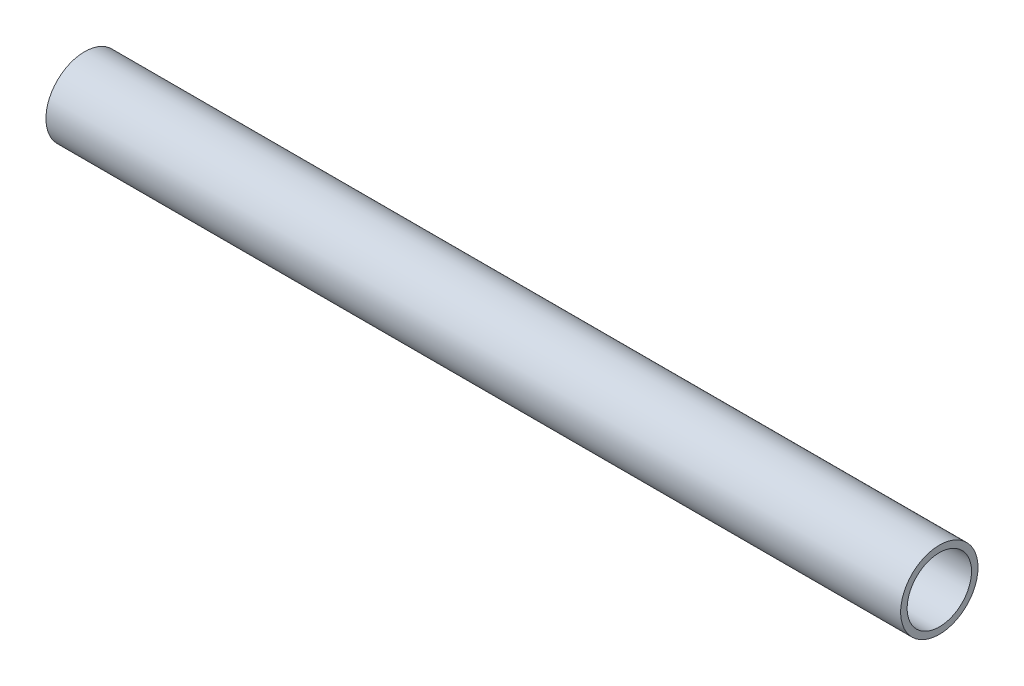
from build123d import *

# Parameters (mm, degrees)
SKETCH11_R              = 6.35
SKETCH11_R_2            = 5.2832
PIPE_0_5_SCH_40_1_DEPTH = 140.366761627


with BuildPart() as part:
    # Sketch11 → Pipe 0.5 SCH 40(1) (new body)
    with BuildSketch(Plane(origin=(-106.534019987, 1471.859674504, 0), x_dir=(0, 1, 0), z_dir=(1, 0, 0))):
        Circle(SKETCH11_R)
        Circle(SKETCH11_R_2, mode=Mode.SUBTRACT)
    extrude(amount=PIPE_0_5_SCH_40_1_DEPTH)


solid = part.part
